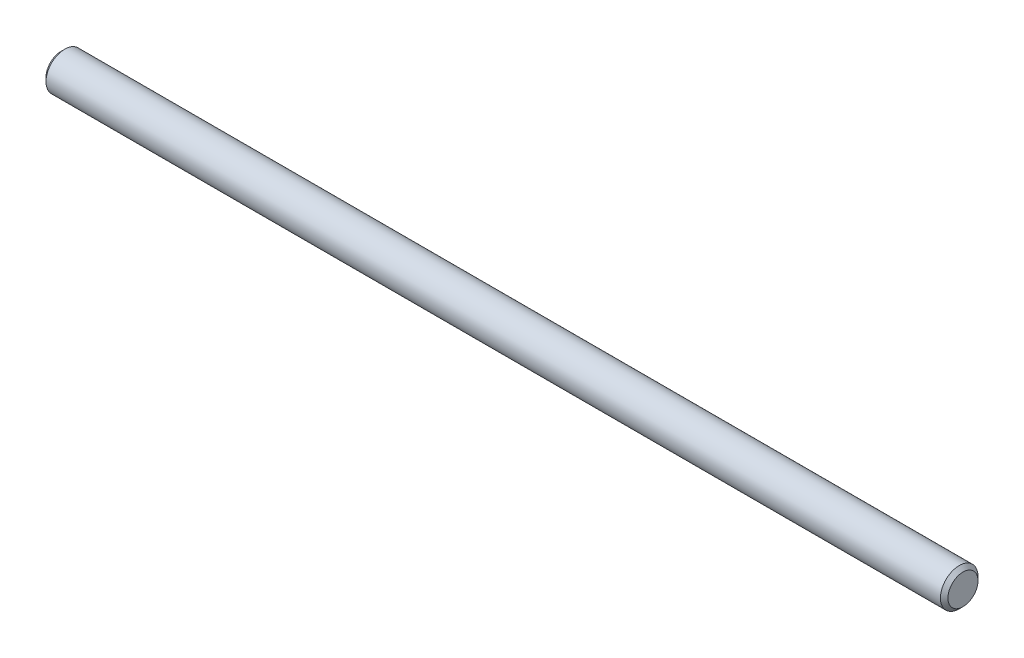
from build123d import *

# Parameters (mm, degrees)
SKETCH2_R           = 3.175
EXTRUDE1_DEPTH      = 76.2
EXTRUDE1_DEPTH_BACK = 76.2
CHAMFER1_SIZE       = 0.635


with BuildPart() as part:
    # Sketch2 → Extrude1 (new body, two sides)
    with BuildSketch(Plane(origin=(0, 0, 0), x_dir=(0, 0, -1), z_dir=(1, 0, 0))) as extrude1_sk:
        Circle(SKETCH2_R)
    extrude(amount=EXTRUDE1_DEPTH)
    extrude(extrude1_sk.sketch, amount=-EXTRUDE1_DEPTH_BACK)

    # Chamfer1
    chamfer1_edges = [part.edges().sort_by_distance(p)[0] for p in [
        (-76.2, 0, 3.175),
        (76.2, 0, 3.175),
    ]]
    chamfer(chamfer1_edges, length=CHAMFER1_SIZE)


solid = part.part
